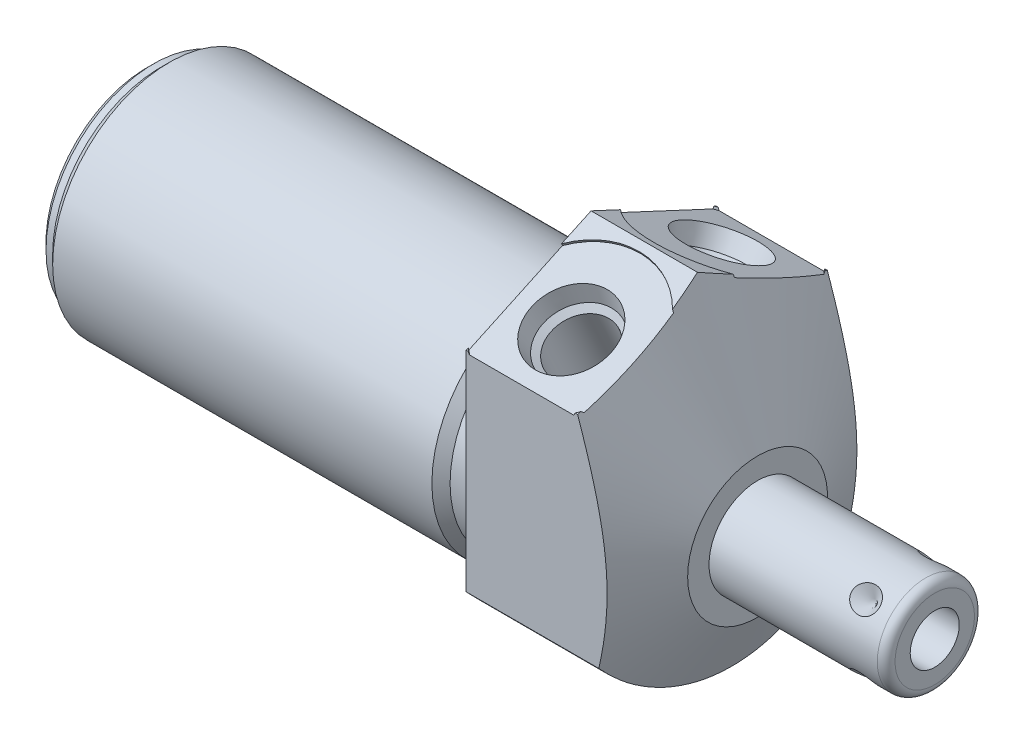
from build123d import *

# Parameters (mm, degrees)
SKETCH1_R           = 19.05
EXTRUDE1_DEPTH      = 19.05
EXTRUDE1_DEPTH_BACK = 50.8
CUT_EXTRUDE1_REACH  = 52.8
SKETCH2_R           = 19.05
SKETCH2_R_2         = 13.3604
CUT_EXTRUDE3_REACH  = 21.05
SKETCH19_R          = 8.6614
CUT_EXTRUDE4_DEPTH  = 0.254
SKETCH20_R          = 8.6614
CUT_EXTRUDE5_DEPTH  = 0.254
CHAMFER1_SIZE       = 0.762
CIRPATTERN1_COUNT   = 4


with BuildPart() as part:
    # Sketch1 → Extrude1 (new body, two sides)
    with BuildSketch(Plane(origin=(0, 0, 0), x_dir=(0, 0, -1), z_dir=(1, 0, 0))) as extrude1_sk:
        Circle(SKETCH1_R)
    extrude(amount=EXTRUDE1_DEPTH)
    extrude(extrude1_sk.sketch, amount=-EXTRUDE1_DEPTH_BACK)

    # Sketch2 → Cut-Extrude1 (cut, up to next)
    with BuildSketch(Plane(origin=(0, 0, 0), x_dir=(0, 0, -1), z_dir=(1, 0, 0)), mode=Mode.PRIVATE) as cut_extrude1_sk1:
        Circle(SKETCH2_R)
        with Locations((0, -4.7498)):
            Circle(SKETCH2_R_2, mode=Mode.SUBTRACT)
    cut_extrude1_tool1 = extrude(cut_extrude1_sk1.sketch, amount=-CUT_EXTRUDE1_REACH, mode=Mode.PRIVATE) & part.part
    add(cut_extrude1_tool1.solids().sort_by_distance((0, 0, 18.511185))[0], mode=Mode.SUBTRACT)

    # Sketch4 → Cut-Extrude3 (cut, up to next)
    with BuildSketch(Plane.ZY, mode=Mode.PRIVATE) as cut_extrude3_sk1:
        with BuildLine():
            Line((14.2875, -12.600390619), (14.2875, 11.344778237))
            Line((14.2875, 11.344778237), (0, 18.007148903))
            Line((0, 18.007148903), (-14.2875, 11.344778237))
            Line((-14.2875, 11.344778237), (-14.2875, -12.600390619))
            ThreePointArc((-14.2875, -12.600390619), (0, 19.05), (14.2875, -12.600390619))
        make_face()
    cut_extrude3_tool1 = extrude(cut_extrude3_sk1.sketch, amount=-CUT_EXTRUDE3_REACH, mode=Mode.PRIVATE) & part.part
    add(cut_extrude3_tool1.solids().sort_by_distance((0, -0.627806, 14.782814))[0], mode=Mode.SUBTRACT)

    # Sketch6 → Cut-Revolve2 (revolve, cut)
    with BuildSketch(Plane.XY, mode=Mode.PRIVATE) as cut_revolve2_sk:
        Polygon((12.169188023, 18.007148903), (19.05, 3.2512), (19.05, 18.007148903), align=None)
    revolve(cut_revolve2_sk.sketch.rotate(Axis((1.987224567, -4.7498, 0), (1, 0, 0)), 270), axis=Axis((1.987224567, -4.7498, 0), (1, 0, 0)), mode=Mode.SUBTRACT)  # turned: the seam where the file's is

    # S2D0002 → Cut-Revolve3 (revolve, cut)
    with BuildSketch(Plane(origin=(6.35, 13.712414668, 8.609072086), x_dir=(0, 0.422618262, -0.906307787), z_dir=(1, 0, 0))):
        Polygon((0, 0), (4.5466, 0), (4.106586662, -2.0701), (3.4544, -2.722286662), (3.4544, -12.192), (0, -12.192), align=None)
    revolve(axis=Axis((6.35, 2.110224902, 3.198882147), (0, 0.906307787, 0.422618262)), mode=Mode.SUBTRACT)

    # Sketch19 → Cut-Extrude4 (cut)
    with BuildSketch(Plane(origin=(0, 14.790960552, 6.897138177), x_dir=(1, 0, 0), z_dir=(0, 0.906307787, 0.422618262))):
        with Locations((6.35, -2.00735222)):
            Circle(SKETCH19_R)
    extrude(amount=-CUT_EXTRUDE4_DEPTH, mode=Mode.SUBTRACT)

    # Sketch8 → Cut-Revolve4 (revolve, cut)
    with BuildSketch(Plane(origin=(6.35, 13.712414668, -8.609072086), x_dir=(0, -0.422618262, -0.906307787), z_dir=(1, 0, 0))):
        Polygon((0, 0), (4.5466, 0), (4.106586662, -2.0701), (3.4544, -2.722286662), (3.4544, -12.192), (0, -12.192), align=None)
    revolve(axis=Axis((6.35, 2.110224902, -3.198882147), (0, 0.906307787, -0.422618262)), mode=Mode.SUBTRACT)

    # Sketch20 → Cut-Extrude5 (cut)
    with BuildSketch(Plane(origin=(0, 14.790960552, -6.897138177), x_dir=(1, 0, 0), z_dir=(0, 0.906307787, -0.422618262))):
        with Locations((6.35, 2.00735222)):
            Circle(SKETCH20_R)
    extrude(amount=-CUT_EXTRUDE5_DEPTH, mode=Mode.SUBTRACT)

    # Sketch10 → Cut-Revolve6 (revolve, cut)
    with BuildSketch(Plane.XY, mode=Mode.PRIVATE) as cut_revolve6_sk:
        Polygon((0, 8.6106), (0, 7.5692), (-3.81, 7.5692), (-4.8514, 8.6106), align=None)
    revolve(cut_revolve6_sk.sketch.rotate(Axis((-5.09397, -4.7498, 0), (1, 0, 0)), 90), axis=Axis((-5.09397, -4.7498, 0), (1, 0, 0)), mode=Mode.SUBTRACT)  # turned: the seam where the file's is

    # Sketch12 → Cut-Revolve8 (revolve, cut)
    with BuildSketch(Plane.XY, mode=Mode.PRIVATE) as cut_revolve8_sk:
        Polygon((-50.8, 8.6106), (-50.8, 7.5692), (-49.276, 7.5692), (-48.2346, 8.6106), align=None)
    revolve(cut_revolve8_sk.sketch.rotate(Axis((-50.92827, -4.7498, 0), (1, 0, 0)), 90), axis=Axis((-50.92827, -4.7498, 0), (1, 0, 0)), mode=Mode.SUBTRACT)  # turned: the seam where the file's is

    # Chamfer1
    chamfer1_edges = [part.edges().sort_by_distance(p)[0] for p in [
        (-50.8, -4.7498, -12.319),
    ]]
    chamfer(chamfer1_edges, length=CHAMFER1_SIZE)

    # Sketch13 → Revolve1 (revolve)
    with BuildSketch(Plane(origin=(0, 0, 0), x_dir=(0, -1, 0), z_dir=(0, 0, 1)), mode=Mode.PRIVATE) as revolve1_sk:
        with BuildLine():
            Line((4.7498, 19.05), (4.7498, 39.3192))
            Line((4.7498, 39.3192), (9.29005, 39.3192))
            ThreePointArc((9.29005, 39.3192), (10.00847049, 39.02162049), (10.30605, 38.3032))
            Line((10.30605, 38.3032), (10.30605, 19.05))
            Line((10.30605, 19.05), (4.7498, 19.05))
        make_face()
    revolve(revolve1_sk.sketch.rotate(Axis((18.03654, -4.7498, 0), (1, 0, 0)), 270), axis=Axis((18.03654, -4.7498, 0), (1, 0, 0)))  # turned: the seam where the file's is

    # S2D0001 → Cut-Revolve9 (revolve, cut)
    with BuildSketch(Plane(origin=(39.3192, -7.5565, 0), x_dir=(0, -1, 0), z_dir=(0, 0, 1)), mode=Mode.PRIVATE) as cut_revolve9_sk:
        Polygon((0, 0), (0, -10.16), (-2.8067, -11.846435499), (-2.8067, 0), align=None)
    revolve(cut_revolve9_sk.sketch.rotate(Axis((26.880442726, -4.7498, 0), (1, 0, 0)), 270), axis=Axis((26.880442726, -4.7498, 0), (1, 0, 0)), mode=Mode.SUBTRACT)  # turned: the seam where the file's is

    # Sketch16 → Cut-Revolve10 (revolve, cut)
    with BuildSketch(Plane(origin=(35.3568, -0.820937947, -3.928862053), x_dir=(-1, 0, 0), z_dir=(0, -0.707106781, -0.707106781)), mode=Mode.PRIVATE) as cut_revolve10_sk:
        Polygon((0, 0), (1.5875, 0), (0, -1.5875), align=None)
    cut_revolve10 = revolve(cut_revolve10_sk.sketch.rotate(Axis((35.3568, -3.280818463, -1.468981537), (0, 0.707106781, -0.707106781)), 90), axis=Axis((35.3568, -3.280818463, -1.468981537), (0, 0.707106781, -0.707106781)), mode=Mode.SUBTRACT)  # turned: the seam where the file's is

    # CirPattern1: Cut-Revolve10 ×4 about axis
    cirpattern1_axis = Axis((18.03654, -4.7498, 0), (-1, 0, 0))
    for i in range(1, CIRPATTERN1_COUNT):
        add(cut_revolve10.rotate(cirpattern1_axis, i * 360 / CIRPATTERN1_COUNT), mode=Mode.SUBTRACT)


solid = part.part
